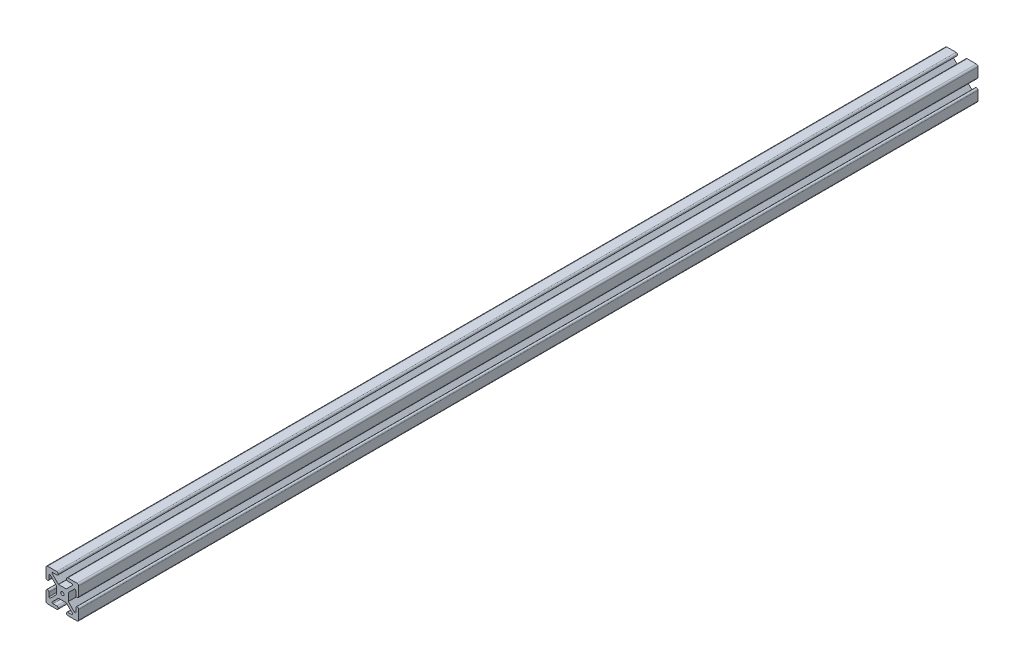
from build123d import *

# Parameters (mm, degrees)
SKETCH1_R           = 1
BOSS_EXTRUDE1_DEPTH = 550


with BuildPart() as part:
    # Sketch1 → Boss-Extrude1 (new body)
    with BuildSketch(Plane.XY.offset(50)):
        with BuildLine():
            Line((-10, 9), (-10, 3.4))
            ThreePointArc((-10, 3.4), (-9.1, 2.5), (-8.2, 3.4))
            Line((-8.2, 3.4), (-8.2, 5.75))
            ThreePointArc((-8.2, 5.75), (-7.891341716, 6.211939766), (-7.346446609, 6.103553391))
            Line((-7.346446609, 6.103553391), (-3.656030738, 2.384202014))
            ThreePointArc((-3.656030738, 2.384202014), (-3.651519225, 2.367364818), (-3.65, 2.35))
            Line((-3.65, 2.35), (-3.65, -2.35))
            ThreePointArc((-3.65, -2.35), (-3.651519225, -2.367364818), (-3.656030738, -2.384202014))
            Line((-3.656030738, -2.384202014), (-7.346446609, -6.103553391))
            ThreePointArc((-7.346446609, -6.103553391), (-7.891341716, -6.211939766), (-8.2, -5.75))
            Line((-8.2, -5.75), (-8.2, -3.4))
            ThreePointArc((-8.2, -3.4), (-9.1, -2.5), (-10, -3.4))
            Line((-10, -3.4), (-10, -9))
            ThreePointArc((-10, -9), (-9.707106781, -9.707106781), (-9, -10))
            Line((-9, -10), (-3.4, -10))
            ThreePointArc((-3.4, -10), (-2.5, -9.1), (-3.4, -8.2))
            Line((-3.4, -8.2), (-5.75, -8.2))
            ThreePointArc((-5.75, -8.2), (-6.211939766, -7.891341716), (-6.103553391, -7.346446609))
            Line((-6.103553391, -7.346446609), (-2.443969262, -3.715797986))
            ThreePointArc((-2.443969262, -3.715797986), (-2.407357644, -3.668084796), (-2.35, -3.65))
            Line((-2.35, -3.65), (2.35, -3.65))
            ThreePointArc((2.35, -3.65), (2.407357644, -3.668084796), (2.443969262, -3.715797986))
            Line((2.443969262, -3.715797986), (6.103553391, -7.346446609))
            ThreePointArc((6.103553391, -7.346446609), (6.211939766, -7.891341716), (5.75, -8.2))
            Line((5.75, -8.2), (3.4, -8.2))
            ThreePointArc((3.4, -8.2), (2.5, -9.1), (3.4, -10))
            Line((3.4, -10), (9, -10))
            ThreePointArc((9, -10), (9.707106781, -9.707106781), (10, -9))
            Line((10, -9), (10, -3.4))
            ThreePointArc((10, -3.4), (9.1, -2.5), (8.2, -3.4))
            Line((8.2, -3.4), (8.2, -5.75))
            ThreePointArc((8.2, -5.75), (7.891341716, -6.211939766), (7.346446609, -6.103553391))
            Line((7.346446609, -6.103553391), (3.656030738, -2.384202014))
            ThreePointArc((3.656030738, -2.384202014), (3.651519225, -2.367364818), (3.65, -2.35))
            Line((3.65, -2.35), (3.65, 2.35))
            ThreePointArc((3.65, 2.35), (3.651519225, 2.367364818), (3.656030738, 2.384202014))
            Line((3.656030738, 2.384202014), (7.346446609, 6.103553391))
            ThreePointArc((7.346446609, 6.103553391), (7.891341716, 6.211939766), (8.2, 5.75))
            Line((8.2, 5.75), (8.2, 3.4))
            ThreePointArc((8.2, 3.4), (9.1, 2.5), (10, 3.4))
            Line((10, 3.4), (10, 9))
            ThreePointArc((10, 9), (9.707106781, 9.707106781), (9, 10))
            Line((9, 10), (3.4, 10))
            ThreePointArc((3.4, 10), (2.5, 9.1), (3.4, 8.2))
            Line((3.4, 8.2), (5.75, 8.2))
            ThreePointArc((5.75, 8.2), (6.211939766, 7.891341716), (6.103553391, 7.346446609))
            Line((6.103553391, 7.346446609), (2.443969262, 3.715797986))
            ThreePointArc((2.443969262, 3.715797986), (2.407357644, 3.668084796), (2.35, 3.65))
            Line((2.35, 3.65), (-2.35, 3.65))
            ThreePointArc((-2.35, 3.65), (-2.407357644, 3.668084796), (-2.443969262, 3.715797986))
            Line((-2.443969262, 3.715797986), (-6.103553391, 7.346446609))
            ThreePointArc((-6.103553391, 7.346446609), (-6.211939766, 7.891341716), (-5.75, 8.2))
            Line((-5.75, 8.2), (-3.4, 8.2))
            ThreePointArc((-3.4, 8.2), (-2.5, 9.1), (-3.4, 10))
            Line((-3.4, 10), (-9, 10))
            ThreePointArc((-9, 10), (-9.707106781, 9.707106781), (-10, 9))
        make_face()
        Circle(SKETCH1_R, mode=Mode.SUBTRACT)
    extrude(amount=-BOSS_EXTRUDE1_DEPTH)


solid = part.part
